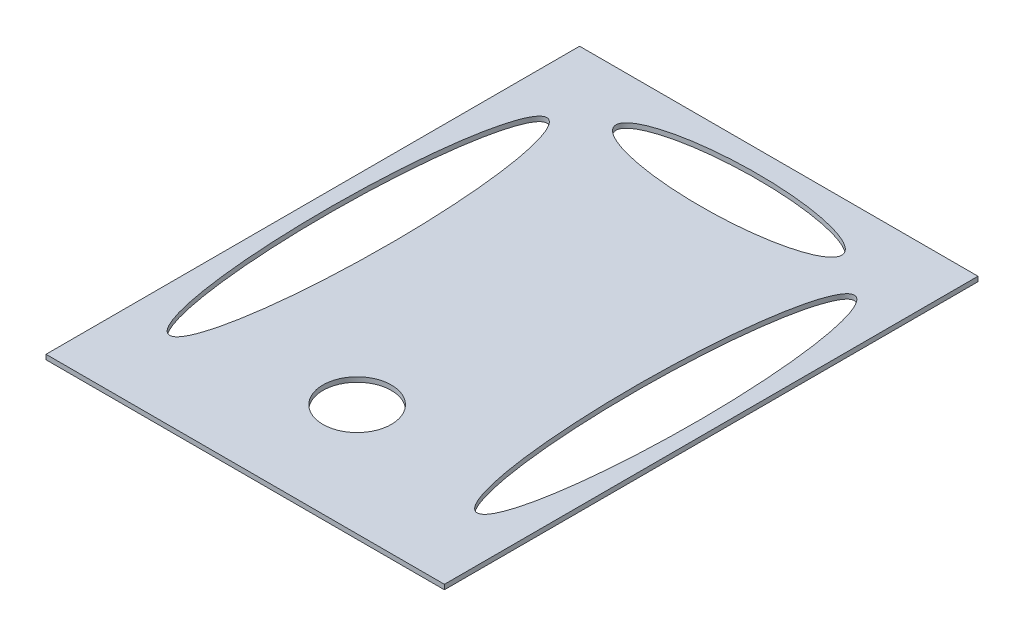
from build123d import *

# Parameters (mm, degrees)
SKETCH_1_W          = 417
SKETCH_1_H          = 558.5
EXTRUDE_1_DEPTH     = 5
SKETCH_2_R          = 35.8
SKETCH_2_RX         = 197.413092706
SKETCH_2_RY         = 32.235751742
SKETCH_2_RX_2       = 118.17560442
SKETCH_2_RY_2       = 29.640592247
CUT_EXTRUDE_1_DEPTH = 6


with BuildPart() as part:
    # 草图1 → 凸台-拉伸1 (new body)
    with BuildSketch(Plane(origin=(0, 0, 0), x_dir=(1, 0, 0), z_dir=(0, 1, 0))):
        with Locations((160.920077933, 225.374515726)):
            Rectangle(SKETCH_1_W, SKETCH_1_H)
    extrude(amount=EXTRUDE_1_DEPTH)

    # 草图2 → 切除-拉伸1 (cut, through all)
    with BuildSketch(Plane(origin=(0, 5, 0), x_dir=(1, 0, 0), z_dir=(0, 1, 0))):
        with Locations((160.920077933, 63.250515726)):
            Circle(SKETCH_2_R)
        with Locations(Location((0, 225.374515726), (0, 0, 90))):
            Ellipse(SKETCH_2_RX, SKETCH_2_RY)
        with Locations(Location((160.920077933, 452.428200679), (0, 0, 180))):
            Ellipse(SKETCH_2_RX_2, SKETCH_2_RY_2)
        with Locations(Location((321.840155866, 225.374515726), (0, 0, 90))):
            Ellipse(SKETCH_2_RX, SKETCH_2_RY)
    extrude(amount=-CUT_EXTRUDE_1_DEPTH, mode=Mode.SUBTRACT)


solid = part.part
